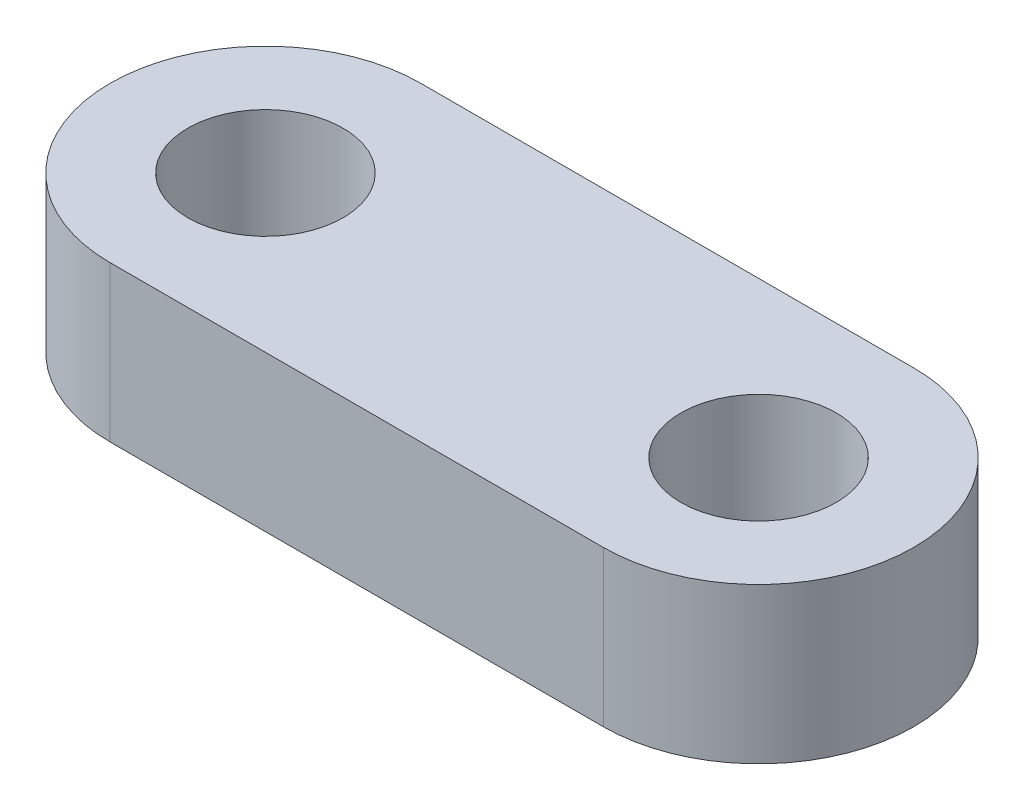
from build123d import *

# Parameters (mm, degrees)
SKETCH1_R           = 1
BOSS_EXTRUDE1_DEPTH = 2


with BuildPart() as part:
    # Sketch1 → Boss-Extrude1 (new body)
    with BuildSketch(Plane(origin=(0, 0, 0), x_dir=(1, 0, 0), z_dir=(0, 1, 0))):
        with BuildLine():
            Line((-3.175, 2), (3.175, 2))
            ThreePointArc((3.175, 2), (5.175, 0), (3.175, -2))
            Line((3.175, -2), (-3.175, -2))
            ThreePointArc((-3.175, -2), (-5.175, 0), (-3.175, 2))
        make_face()
        with Locations((3.175, 0)):
            Circle(SKETCH1_R, mode=Mode.SUBTRACT)
        with Locations((-3.175, 0)):
            Circle(SKETCH1_R, mode=Mode.SUBTRACT)
    extrude(amount=BOSS_EXTRUDE1_DEPTH)


solid = part.part
